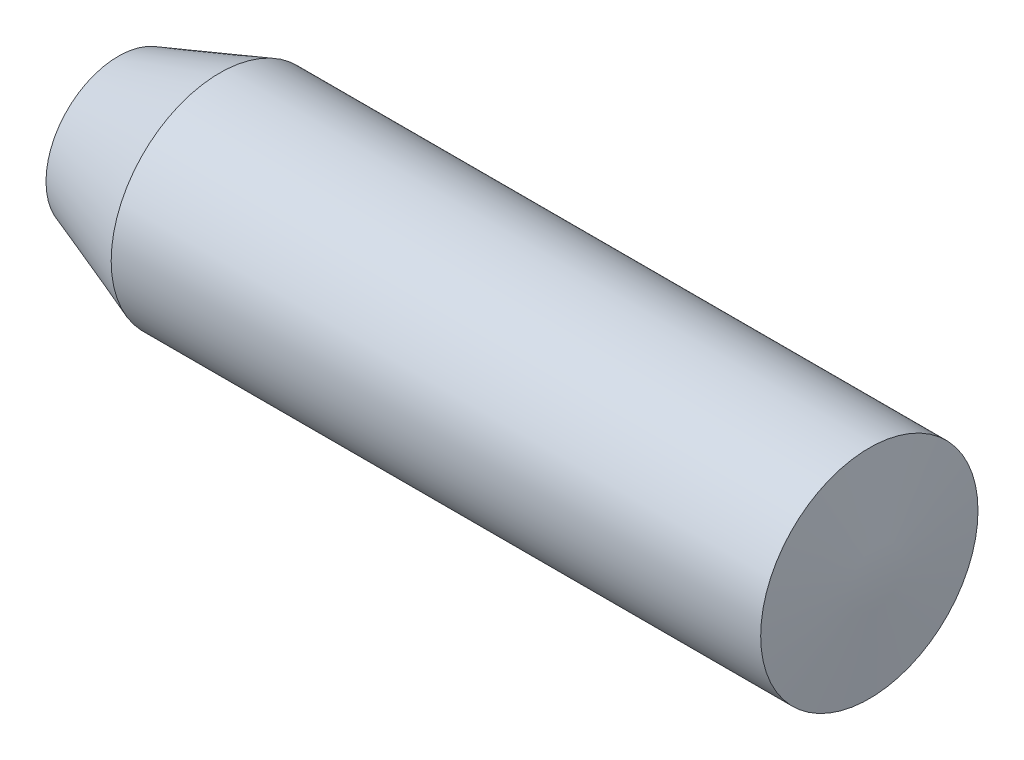
from build123d import *


with BuildPart() as part:
    # Sketch1 → Revolve1 (revolve)
    with BuildSketch(Plane.XY):
        Polygon((0, 0), (0, 169.096871333), (237.245718475, 254), (1755.508482821, 254), (1778, 0), align=None)
    revolve(axis=Axis((0, 0, 0), (1, 0, 0)))


solid = part.part
